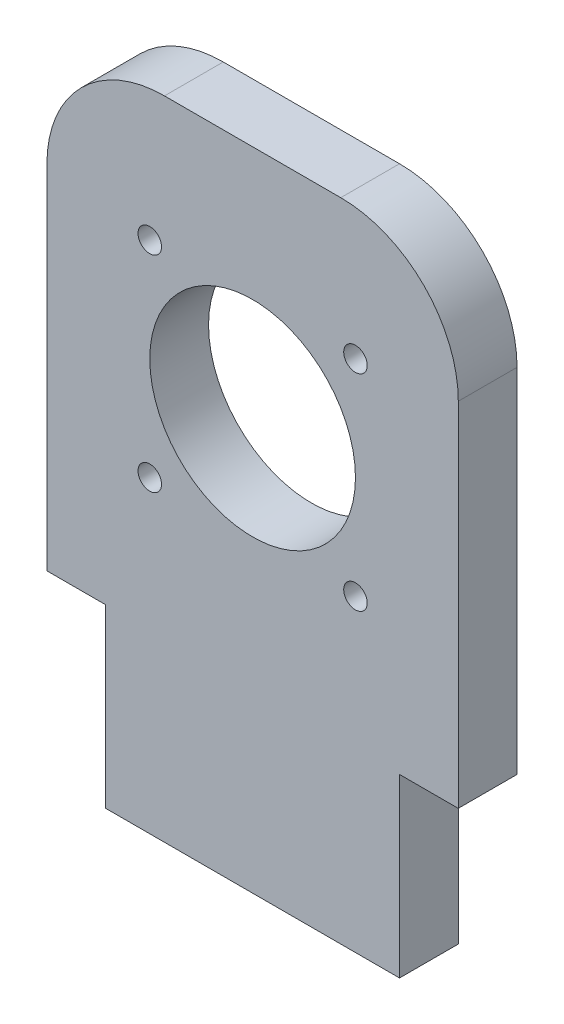
from build123d import *

# Parameters (mm, degrees)
SKETCH1_W           = 70
SKETCH1_H           = 80
SKETCH1_R           = 17.5
SKETCH1_W_2         = 50
SKETCH1_H_2         = 30
BOSS_EXTRUDE1_DEPTH = 10
FILLET1_R           = 20
SKETCH2_R           = 2
CUT_EXTRUDE1_DEPTH  = 10


with BuildPart() as part:
    # Sketch1 → Boss-Extrude1 (new body)
    with BuildSketch(Plane.XY):
        with Locations((35, -40)):
            Rectangle(SKETCH1_W, SKETCH1_H)
        with Locations((35, -40)):
            Circle(SKETCH1_R, mode=Mode.SUBTRACT)
        with Locations((35, -95)):
            Rectangle(SKETCH1_W_2, SKETCH1_H_2)
    extrude(amount=BOSS_EXTRUDE1_DEPTH)

    # Fillet1
    fillet1_edges = [part.edges().sort_by_distance(p)[0] for p in [
        (70, 0, 5),
        (0, 0, 5),
    ]]
    fillet(fillet1_edges, radius=FILLET1_R)

    # Sketch2 → Cut-Extrude1 (cut)
    with BuildSketch(Plane.XY.offset(10)):
        with Locations((17.5, -22.5)):
            Circle(SKETCH2_R)
        with Locations((52.5, -22.5)):
            Circle(SKETCH2_R)
        with Locations((52.5, -57.5)):
            Circle(SKETCH2_R)
        with Locations((17.5, -57.5)):
            Circle(SKETCH2_R)
    extrude(amount=-CUT_EXTRUDE1_DEPTH, mode=Mode.SUBTRACT)


solid = part.part
